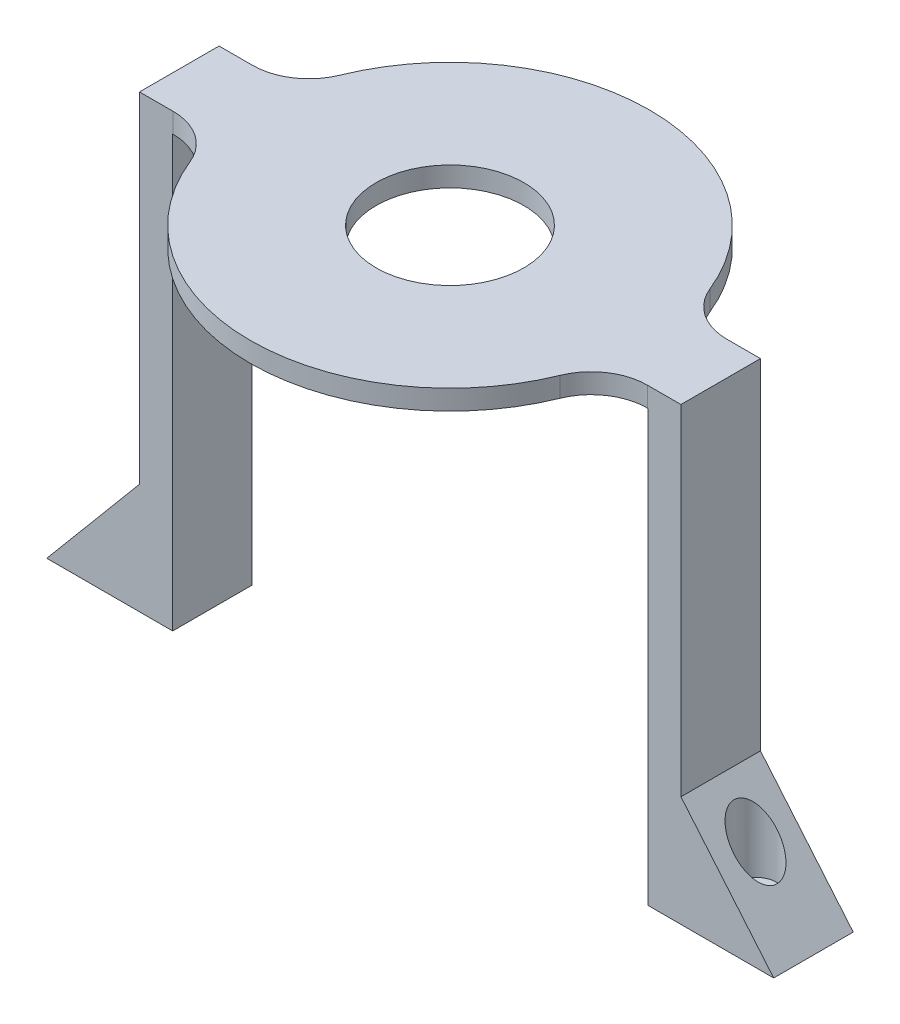
from build123d import *

# Parameters (mm, degrees)
SKETCH8_R           = 11.15
BOSS_EXTRUDE4_DEPTH = 3
BOSS_EXTRUDE5_DEPTH = 12
SKETCH11_R          = 3.25
CUT_EXTRUDE3_DEPTH  = 13.2
SKETCH14_R          = 1.7
CUT_EXTRUDE4_DEPTH  = 17.684550296
FILLET1_R           = 8.5


with BuildPart() as part:
    # Sketch8 → Boss-Extrude4 (new body)
    with BuildSketch(Plane(origin=(0, 0, 0), x_dir=(1, 0, 0), z_dir=(0, 1, 0))):
        with BuildLine():
            Line((-35.85, -6), (-29.521443478, -6))
            ThreePointArc((-29.521443478, -6), (0, -30.125), (29.521443478, -6))
            Line((29.521443478, -6), (35.85, -6))
            Line((35.85, -6), (35.85, 6))
            Line((35.85, 6), (29.521443478, 6))
            ThreePointArc((29.521443478, 6), (0, 30.125), (-29.521443478, 6))
            Line((-29.521443478, 6), (-35.85, 6))
            Line((-35.85, 6), (-35.85, -6))
        make_face()
        Circle(SKETCH8_R, mode=Mode.SUBTRACT)
    extrude(amount=BOSS_EXTRUDE4_DEPTH)

    # Sketch9 → Boss-Extrude5 (add)
    with BuildSketch(Plane.XY.offset(6)):
        Polygon((-35.85, 3), (-35.85, -64.95), (-54.85, -64.95), (-40.85, -48.265449704), (-40.85, 3), align=None)
    boss_extrude5 = extrude(amount=-BOSS_EXTRUDE5_DEPTH)

    # Sketch11 → Cut-Extrude3 (cut)
    with BuildSketch(Plane.ZX.offset(-48.265449704)):
        with Locations((0, -46.1)):
            Circle(SKETCH11_R)
    cut_extrude3 = extrude(amount=-CUT_EXTRUDE3_DEPTH, mode=Mode.SUBTRACT)

    # Sketch14 → Cut-Extrude4 (cut, through all)
    with BuildSketch(Plane.ZX.offset(-48.265449704)):
        with Locations((0, -46.1)):
            Circle(SKETCH14_R)
    cut_extrude4 = extrude(amount=-CUT_EXTRUDE4_DEPTH, mode=Mode.SUBTRACT)

    # Mirror3: Boss-Extrude5, Cut-Extrude3, Cut-Extrude4 across plane
    add(boss_extrude5.mirror(Plane(origin=(0, 0, 0), x_dir=(0, 0, 1), z_dir=(1, 0, 0))))
    add(cut_extrude3.mirror(Plane(origin=(0, 0, 0), x_dir=(0, 0, 1), z_dir=(1, 0, 0))), mode=Mode.SUBTRACT)
    add(cut_extrude4.mirror(Plane(origin=(0, 0, 0), x_dir=(0, 0, 1), z_dir=(1, 0, 0))), mode=Mode.SUBTRACT)

    # Fillet1
    fillet1_edges = [part.edges().sort_by_distance(p)[0] for p in [
        (-29.521443478, 1.5, -6),
        (29.521443478, 1.5, -6),
        (29.521443478, 1.5, 6),
        (-29.521443478, 1.5, 6),
    ]]
    fillet(fillet1_edges, radius=FILLET1_R)


solid = part.part
